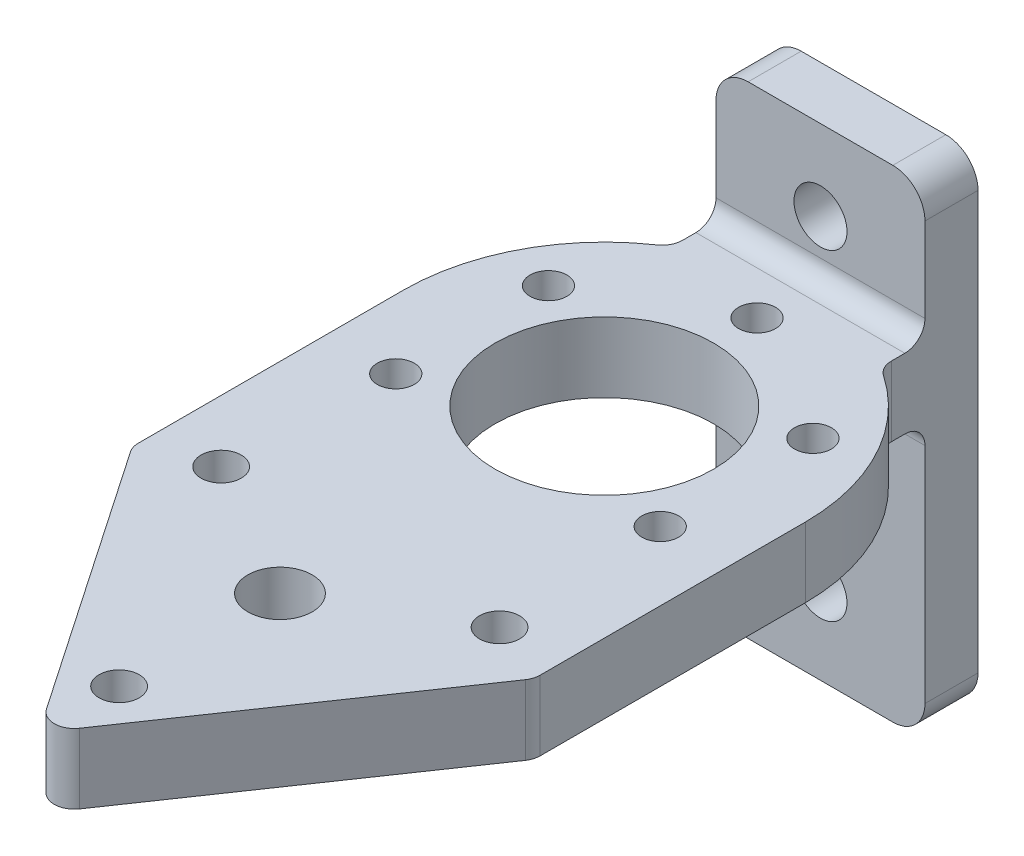
from build123d import *

# Parameters (mm, degrees)
ESQUISSE1_W             = 13
ESQUISSE1_H             = 30
ESQUISSE1_R             = 1.65
BOSS_EXTRU_1_DEPTH      = 3.3
CONG_1_R                = 2
ESQUISSE2_W             = 13
ESQUISSE2_H             = 4.34999702
BOSS_EXTRU_2_DEPTH      = 2.77
ESQUISSE4_R             = 6.8
BOSS_EXTRU_4_DEPTH      = 4.349997
ESQUISSE6_R             = 1.15
ENL_V_MAT_EXTRU_2_DEPTH = 22.49999702
ESQUISSE8_R             = 2
ESQUISSE8_R_2           = 1.25
BOSS_EXTRU_5_DEPTH      = 4.349997
CONG_2_R                = 1.25


with BuildPart() as part:
    # Esquisse1 → Boss.-Extru.1 (new body)
    with BuildSketch(Plane.XY):
        Rectangle(ESQUISSE1_W, ESQUISSE1_H)
        with Locations((0, 10)):
            Circle(ESQUISSE1_R, mode=Mode.SUBTRACT)
        with Locations((0, -10)):
            Circle(ESQUISSE1_R, mode=Mode.SUBTRACT)
    extrude(amount=BOSS_EXTRU_1_DEPTH)

    # Congé1
    cong_1_edges = [part.edges().sort_by_distance(p)[0] for p in [
        (6.5, -15, 1.65),
        (-6.5, -15, 1.65),
        (-6.5, 15, 1.65),
        (6.5, 15, 1.65),
    ]]
    fillet(cong_1_edges, radius=CONG_1_R)

    # Esquisse2 → Boss.-Extru.2 (add)
    with BuildSketch(Plane.XY.offset(3.3)):
        with Locations((0, 4.32499851)):
            Rectangle(ESQUISSE2_W, ESQUISSE2_H)
    extrude(amount=BOSS_EXTRU_2_DEPTH)

    # Esquisse4 → Boss.-Extru.4 (add)
    with BuildSketch(Plane(origin=(0, 6.49999702, 0), x_dir=(1, 0, 0), z_dir=(0, 1, 0))):
        with BuildLine():
            Line((-6.5, -6.07), (6.5, -6.07))
            ThreePointArc((6.5, -6.07), (12.5, -16.747078252), (6.5, -27.424156504))
            Line((6.5, -27.424156504), (-6.5, -27.424156504))
            ThreePointArc((-6.5, -27.424156504), (-12.5, -16.747078252), (-6.5, -6.07))
        make_face()
        with Locations((0, -16.747078252)):
            Circle(ESQUISSE4_R, mode=Mode.SUBTRACT)
    extrude(amount=-BOSS_EXTRU_4_DEPTH)

    # Esquisse6 → Enlèv. mat.-Extru.2 (cut, through all)
    with BuildSketch(Plane(origin=(0, 6.49999702, 0), x_dir=(1, 0, 0), z_dir=(0, 1, 0))):
        with Locations((0, -7.247078252)):
            Circle(ESQUISSE6_R)
        with Locations((-8.227241336, -11.997078252)):
            Circle(ESQUISSE6_R)
        with Locations((8.227241336, -11.997078252)):
            Circle(ESQUISSE6_R)
        with Locations((-8.227241336, -21.497078252)):
            Circle(ESQUISSE6_R)
        with Locations((8.227241336, -21.497078252)):
            Circle(ESQUISSE6_R)
    extrude(amount=-ENL_V_MAT_EXTRU_2_DEPTH, mode=Mode.SUBTRACT)

    # Esquisse8 → Boss.-Extru.5 (add)
    with BuildSketch(Plane(origin=(0, 6.49999702, 0), x_dir=(1, 0, 0), z_dir=(0, 1, 0))):
        with BuildLine():
            Line((0, -51.937078252), (-12.5, -33.625808063))
            Line((-12.5, -33.625808063), (-12.5, -16.747078252))
            ThreePointArc((-12.5, -16.747078252), (-10.897247359, -22.870802609), (-6.5, -27.424156504))
            Line((-6.5, -27.424156504), (6.5, -27.424156504))
            ThreePointArc((6.5, -27.424156504), (10.897247359, -22.870802609), (12.5, -16.747078252))
            Line((12.5, -16.747078252), (12.5, -33.627078252))
            Line((12.5, -33.627078252), (0, -51.937078252))
        make_face()
        with Locations((0, -36.927078252)):
            Circle(ESQUISSE8_R, mode=Mode.SUBTRACT)
        with Locations((8.660254038, -31.927078252)):
            Circle(ESQUISSE8_R_2, mode=Mode.SUBTRACT)
        with Locations((-8.660254038, -31.927078252)):
            Circle(ESQUISSE8_R_2, mode=Mode.SUBTRACT)
        with Locations((0, -46.937078252)):
            Circle(ESQUISSE8_R_2, mode=Mode.SUBTRACT)
    extrude(amount=-BOSS_EXTRU_5_DEPTH)

    # Congé2
    cong_2_edges = [part.edges().sort_by_distance(p)[0] for p in [
        (-12.5, 4.32499852, 33.625808063),
        (0, 4.32499852, 51.937078252),
        (12.5, 4.32499852, 33.627078252),
        (0, 6.49999702, 3.3),
        (0, 2.15, 3.3),
        (6.5, 4.32499851, 6.07),
        (-6.5, 4.32499851, 6.07),
    ]]
    fillet(cong_2_edges, radius=CONG_2_R)


solid = part.part
